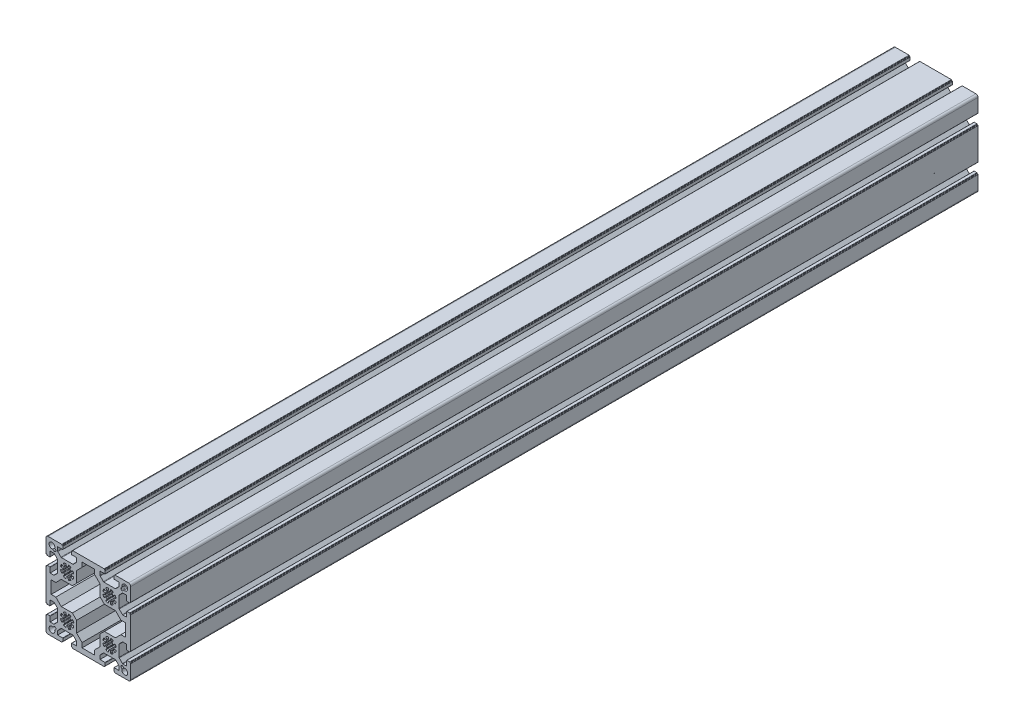
from build123d import *

# Parameters (mm, degrees)
EXTRUDE_1_DEPTH = 1000


with BuildPart() as part:
    # Эскиз1 → Бобышка-Вытянуть1 (new body)
    with BuildSketch(Plane.XY):
        with BuildLine():
            Line((-25, 11.25), (-25, 22.5))
            ThreePointArc((-25, 22.5), (-24.267766953, 24.267766953), (-22.5, 25))
            Line((-22.5, 25), (-11.25, 25))
            Line((-11.25, 25), (-6.4, 25))
            ThreePointArc((-6.4, 25), (-6.187867966, 24.912132034), (-6.1, 24.7))
            Line((-6.1, 24.7), (-6.1, 24.3))
            ThreePointArc((-6.1, 24.3), (-6.012132034, 24.087867966), (-5.8, 24))
            Line((-5.8, 24), (-5.4, 24))
            ThreePointArc((-5.4, 24), (-5.187867966, 23.912132034), (-5.1, 23.7))
            Line((-5.1, 23.7), (-5.1, 20.5))
            ThreePointArc((-5.1, 20.5), (-5.187867966, 20.287867966), (-5.4, 20.2))
            Line((-5.4, 20.2), (-11.25, 20.2))
            Line((-11.25, 20.2), (-11.25, 15.874213562))
            ThreePointArc((-11.25, 15.874213562), (-11.173879533, 15.49153013), (-10.957106781, 15.167106781))
            Line((-10.957106781, 15.167106781), (-7.292893219, 11.502893219))
            ThreePointArc((-7.292893219, 11.502893219), (-6.96846987, 11.286120467), (-6.585786438, 11.21))
            Line((-6.585786438, 11.21), (6.585786438, 11.21))
            ThreePointArc((6.585786438, 11.21), (6.96846987, 11.286120467), (7.292893219, 11.502893219))
            Line((7.292893219, 11.502893219), (10.957106781, 15.167106781))
            ThreePointArc((10.957106781, 15.167106781), (11.173879533, 15.49153013), (11.25, 15.874213562))
            Line((11.25, 15.874213562), (11.25, 20.2))
            Line((11.25, 20.2), (5.4, 20.2))
            ThreePointArc((5.4, 20.2), (5.187867966, 20.287867966), (5.1, 20.5))
            Line((5.1, 20.5), (5.1, 23.7))
            ThreePointArc((5.1, 23.7), (5.187867966, 23.912132034), (5.4, 24))
            Line((5.4, 24), (5.8, 24))
            ThreePointArc((5.8, 24), (6.012132034, 24.087867966), (6.1, 24.3))
            Line((6.1, 24.3), (6.1, 24.7))
            ThreePointArc((6.1, 24.7), (6.187867966, 24.912132034), (6.4, 25))
            Line((6.4, 25), (11.25, 25))
            Line((11.25, 25), (38.75, 25))
            Line((38.75, 25), (43.6, 25))
            ThreePointArc((43.6, 25), (43.812132034, 24.912132034), (43.9, 24.7))
            Line((43.9, 24.7), (43.9, 24.3))
            ThreePointArc((43.9, 24.3), (43.987867966, 24.087867966), (44.2, 24))
            Line((44.2, 24), (44.6, 24))
            ThreePointArc((44.6, 24), (44.812132034, 23.912132034), (44.9, 23.7))
            Line((44.9, 23.7), (44.9, 20.5))
            ThreePointArc((44.9, 20.5), (44.812132034, 20.287867966), (44.6, 20.2))
            Line((44.6, 20.2), (38.75, 20.2))
            Line((38.75, 20.2), (38.75, 15.874213562))
            ThreePointArc((38.75, 15.874213562), (38.826120467, 15.49153013), (39.042893219, 15.167106781))
            Line((39.042893219, 15.167106781), (42.707106781, 11.502893219))
            ThreePointArc((42.707106781, 11.502893219), (43.03153013, 11.286120467), (43.414213562, 11.21))
            Line((43.414213562, 11.21), (56.585786438, 11.21))
            ThreePointArc((56.585786438, 11.21), (56.96846987, 11.286120467), (57.292893219, 11.502893219))
            Line((57.292893219, 11.502893219), (60.957106781, 15.167106781))
            ThreePointArc((60.957106781, 15.167106781), (61.173879533, 15.49153013), (61.25, 15.874213562))
            Line((61.25, 15.874213562), (61.25, 20.2))
            Line((61.25, 20.2), (55.4, 20.2))
            ThreePointArc((55.4, 20.2), (55.187867966, 20.287867966), (55.1, 20.5))
            Line((55.1, 20.5), (55.1, 23.7))
            ThreePointArc((55.1, 23.7), (55.187867966, 23.912132034), (55.4, 24))
            Line((55.4, 24), (55.8, 24))
            ThreePointArc((55.8, 24), (56.012132034, 24.087867966), (56.1, 24.3))
            Line((56.1, 24.3), (56.1, 24.7))
            ThreePointArc((56.1, 24.7), (56.187867966, 24.912132034), (56.4, 25))
            Line((56.4, 25), (61.25, 25))
            Line((61.25, 25), (72.5, 25))
            ThreePointArc((72.5, 25), (74.267766953, 24.267766953), (75, 22.5))
            Line((75, 22.5), (75, 11.25))
            Line((75, 11.25), (75, 6.4))
            ThreePointArc((75, 6.4), (74.912132034, 6.187867966), (74.7, 6.1))
            Line((74.7, 6.1), (74.3, 6.1))
            ThreePointArc((74.3, 6.1), (74.087867966, 6.012132034), (74, 5.8))
            Line((74, 5.8), (74, 5.4))
            ThreePointArc((74, 5.4), (73.912132034, 5.187867966), (73.7, 5.1))
            Line((73.7, 5.1), (70.5, 5.1))
            ThreePointArc((70.5, 5.1), (70.287867966, 5.187867966), (70.2, 5.4))
            Line((70.2, 5.4), (70.2, 11.25))
            Line((70.2, 11.25), (65.874213562, 11.25))
            ThreePointArc((65.874213562, 11.25), (65.49153013, 11.173879533), (65.167106781, 10.957106781))
            Line((65.167106781, 10.957106781), (61.502893219, 7.292893219))
            ThreePointArc((61.502893219, 7.292893219), (61.286120467, 6.96846987), (61.21, 6.585786438))
            Line((61.21, 6.585786438), (61.21, -6.585786438))
            ThreePointArc((61.21, -6.585786438), (61.286120467, -6.96846987), (61.502893219, -7.292893219))
            Line((61.502893219, -7.292893219), (65.167106781, -10.957106781))
            ThreePointArc((65.167106781, -10.957106781), (65.49153013, -11.173879533), (65.874213562, -11.25))
            Line((65.874213562, -11.25), (70.2, -11.25))
            Line((70.2, -11.25), (70.2, -5.4))
            ThreePointArc((70.2, -5.4), (70.287867966, -5.187867966), (70.5, -5.1))
            Line((70.5, -5.1), (73.7, -5.1))
            ThreePointArc((73.7, -5.1), (73.912132034, -5.187867966), (74, -5.4))
            Line((74, -5.4), (74, -5.8))
            ThreePointArc((74, -5.8), (74.087867966, -6.012132034), (74.3, -6.1))
            Line((74.3, -6.1), (74.7, -6.1))
            ThreePointArc((74.7, -6.1), (74.912132034, -6.187867966), (75, -6.4))
            Line((75, -6.4), (75, -11.25))
            Line((75, -11.25), (75, -38.75))
            Line((75, -38.75), (75, -43.6))
            ThreePointArc((75, -43.6), (74.912132034, -43.812132034), (74.7, -43.9))
            Line((74.7, -43.9), (74.3, -43.9))
            ThreePointArc((74.3, -43.9), (74.087867966, -43.987867966), (74, -44.2))
            Line((74, -44.2), (74, -44.6))
            ThreePointArc((74, -44.6), (73.912132034, -44.812132034), (73.7, -44.9))
            Line((73.7, -44.9), (70.5, -44.9))
            ThreePointArc((70.5, -44.9), (70.287867966, -44.812132034), (70.2, -44.6))
            Line((70.2, -44.6), (70.2, -38.75))
            Line((70.2, -38.75), (65.874213562, -38.75))
            ThreePointArc((65.874213562, -38.75), (65.49153013, -38.826120467), (65.167106781, -39.042893219))
            Line((65.167106781, -39.042893219), (61.502893219, -42.707106781))
            ThreePointArc((61.502893219, -42.707106781), (61.286120467, -43.03153013), (61.21, -43.414213562))
            Line((61.21, -43.414213562), (61.21, -56.585786438))
            ThreePointArc((61.21, -56.585786438), (61.286120467, -56.96846987), (61.502893219, -57.292893219))
            Line((61.502893219, -57.292893219), (65.167106781, -60.957106781))
            ThreePointArc((65.167106781, -60.957106781), (65.49153013, -61.173879533), (65.874213562, -61.25))
            Line((65.874213562, -61.25), (70.2, -61.25))
            Line((70.2, -61.25), (70.2, -55.4))
            ThreePointArc((70.2, -55.4), (70.287867966, -55.187867966), (70.5, -55.1))
            Line((70.5, -55.1), (73.7, -55.1))
            ThreePointArc((73.7, -55.1), (73.912132034, -55.187867966), (74, -55.4))
            Line((74, -55.4), (74, -55.8))
            ThreePointArc((74, -55.8), (74.087867966, -56.012132034), (74.3, -56.1))
            Line((74.3, -56.1), (74.7, -56.1))
            ThreePointArc((74.7, -56.1), (74.912132034, -56.187867966), (75, -56.4))
            Line((75, -56.4), (75, -61.25))
            Line((75, -61.25), (75, -72.5))
            ThreePointArc((75, -72.5), (74.267766953, -74.267766953), (72.5, -75))
            Line((72.5, -75), (61.25, -75))
            Line((61.25, -75), (56.4, -75))
            ThreePointArc((56.4, -75), (56.187867966, -74.912132034), (56.1, -74.7))
            Line((56.1, -74.7), (56.1, -74.3))
            ThreePointArc((56.1, -74.3), (56.012132034, -74.087867966), (55.8, -74))
            Line((55.8, -74), (55.4, -74))
            ThreePointArc((55.4, -74), (55.187867966, -73.912132034), (55.1, -73.7))
            Line((55.1, -73.7), (55.1, -70.5))
            ThreePointArc((55.1, -70.5), (55.187867966, -70.287867966), (55.4, -70.2))
            Line((55.4, -70.2), (61.25, -70.2))
            Line((61.25, -70.2), (61.25, -65.874213562))
            ThreePointArc((61.25, -65.874213562), (61.173879533, -65.49153013), (60.957106781, -65.167106781))
            Line((60.957106781, -65.167106781), (57.292893219, -61.502893219))
            ThreePointArc((57.292893219, -61.502893219), (56.96846987, -61.286120467), (56.585786438, -61.21))
            Line((56.585786438, -61.21), (43.414213562, -61.21))
            ThreePointArc((43.414213562, -61.21), (43.03153013, -61.286120467), (42.707106781, -61.502893219))
            Line((42.707106781, -61.502893219), (39.042893219, -65.167106781))
            ThreePointArc((39.042893219, -65.167106781), (38.826120467, -65.49153013), (38.75, -65.874213562))
            Line((38.75, -65.874213562), (38.75, -70.2))
            Line((38.75, -70.2), (44.6, -70.2))
            ThreePointArc((44.6, -70.2), (44.812132034, -70.287867966), (44.9, -70.5))
            Line((44.9, -70.5), (44.9, -73.7))
            ThreePointArc((44.9, -73.7), (44.812132034, -73.912132034), (44.6, -74))
            Line((44.6, -74), (44.2, -74))
            ThreePointArc((44.2, -74), (43.987867966, -74.087867966), (43.9, -74.3))
            Line((43.9, -74.3), (43.9, -74.7))
            ThreePointArc((43.9, -74.7), (43.812132034, -74.912132034), (43.6, -75))
            Line((43.6, -75), (38.75, -75))
            Line((38.75, -75), (11.25, -75))
            Line((11.25, -75), (6.4, -75))
            ThreePointArc((6.4, -75), (6.187867966, -74.912132034), (6.1, -74.7))
            Line((6.1, -74.7), (6.1, -74.3))
            ThreePointArc((6.1, -74.3), (6.012132034, -74.087867966), (5.8, -74))
            Line((5.8, -74), (5.4, -74))
            ThreePointArc((5.4, -74), (5.187867966, -73.912132034), (5.1, -73.7))
            Line((5.1, -73.7), (5.1, -70.5))
            ThreePointArc((5.1, -70.5), (5.187867966, -70.287867966), (5.4, -70.2))
            Line((5.4, -70.2), (11.25, -70.2))
            Line((11.25, -70.2), (11.25, -65.874213562))
            ThreePointArc((11.25, -65.874213562), (11.173879533, -65.49153013), (10.957106781, -65.167106781))
            Line((10.957106781, -65.167106781), (7.292893219, -61.502893219))
            ThreePointArc((7.292893219, -61.502893219), (6.96846987, -61.286120467), (6.585786438, -61.21))
            Line((6.585786438, -61.21), (-6.585786438, -61.21))
            ThreePointArc((-6.585786438, -61.21), (-6.96846987, -61.286120467), (-7.292893219, -61.502893219))
            Line((-7.292893219, -61.502893219), (-10.957106781, -65.167106781))
            ThreePointArc((-10.957106781, -65.167106781), (-11.173879533, -65.49153013), (-11.25, -65.874213562))
            Line((-11.25, -65.874213562), (-11.25, -70.2))
            Line((-11.25, -70.2), (-5.4, -70.2))
            ThreePointArc((-5.4, -70.2), (-5.187867966, -70.287867966), (-5.1, -70.5))
            Line((-5.1, -70.5), (-5.1, -73.7))
            ThreePointArc((-5.1, -73.7), (-5.187867966, -73.912132034), (-5.4, -74))
            Line((-5.4, -74), (-5.8, -74))
            ThreePointArc((-5.8, -74), (-6.012132034, -74.087867966), (-6.1, -74.3))
            Line((-6.1, -74.3), (-6.1, -74.7))
            ThreePointArc((-6.1, -74.7), (-6.187867966, -74.912132034), (-6.4, -75))
            Line((-6.4, -75), (-11.25, -75))
            Line((-11.25, -75), (-22.5, -75))
            ThreePointArc((-22.5, -75), (-24.267766953, -74.267766953), (-25, -72.5))
            Line((-25, -72.5), (-25, -61.25))
            Line((-25, -61.25), (-25, -56.4))
            ThreePointArc((-25, -56.4), (-24.912132034, -56.187867966), (-24.7, -56.1))
            Line((-24.7, -56.1), (-24.3, -56.1))
            ThreePointArc((-24.3, -56.1), (-24.087867966, -56.012132034), (-24, -55.8))
            Line((-24, -55.8), (-24, -55.4))
            ThreePointArc((-24, -55.4), (-23.912132034, -55.187867966), (-23.7, -55.1))
            Line((-23.7, -55.1), (-20.5, -55.1))
            ThreePointArc((-20.5, -55.1), (-20.287867966, -55.187867966), (-20.2, -55.4))
            Line((-20.2, -55.4), (-20.2, -61.25))
            Line((-20.2, -61.25), (-15.874213562, -61.25))
            ThreePointArc((-15.874213562, -61.25), (-15.49153013, -61.173879533), (-15.167106781, -60.957106781))
            Line((-15.167106781, -60.957106781), (-11.502893219, -57.292893219))
            ThreePointArc((-11.502893219, -57.292893219), (-11.286120467, -56.96846987), (-11.21, -56.585786438))
            Line((-11.21, -56.585786438), (-11.21, -43.414213562))
            ThreePointArc((-11.21, -43.414213562), (-11.286120467, -43.03153013), (-11.502893219, -42.707106781))
            Line((-11.502893219, -42.707106781), (-15.167106781, -39.042893219))
            ThreePointArc((-15.167106781, -39.042893219), (-15.49153013, -38.826120467), (-15.874213562, -38.75))
            Line((-15.874213562, -38.75), (-20.2, -38.75))
            Line((-20.2, -38.75), (-20.2, -44.6))
            ThreePointArc((-20.2, -44.6), (-20.287867966, -44.812132034), (-20.5, -44.9))
            Line((-20.5, -44.9), (-23.7, -44.9))
            ThreePointArc((-23.7, -44.9), (-23.912132034, -44.812132034), (-24, -44.6))
            Line((-24, -44.6), (-24, -44.2))
            ThreePointArc((-24, -44.2), (-24.087867966, -43.987867966), (-24.3, -43.9))
            Line((-24.3, -43.9), (-24.7, -43.9))
            ThreePointArc((-24.7, -43.9), (-24.912132034, -43.812132034), (-25, -43.6))
            Line((-25, -43.6), (-25, -38.75))
            Line((-25, -38.75), (-25, -11.25))
            Line((-25, -11.25), (-25, -6.4))
            ThreePointArc((-25, -6.4), (-24.912132034, -6.187867966), (-24.7, -6.1))
            Line((-24.7, -6.1), (-24.3, -6.1))
            ThreePointArc((-24.3, -6.1), (-24.087867966, -6.012132034), (-24, -5.8))
            Line((-24, -5.8), (-24, -5.4))
            ThreePointArc((-24, -5.4), (-23.912132034, -5.187867966), (-23.7, -5.1))
            Line((-23.7, -5.1), (-20.5, -5.1))
            ThreePointArc((-20.5, -5.1), (-20.287867966, -5.187867966), (-20.2, -5.4))
            Line((-20.2, -5.4), (-20.2, -11.25))
            Line((-20.2, -11.25), (-15.874213562, -11.25))
            ThreePointArc((-15.874213562, -11.25), (-15.49153013, -11.173879533), (-15.167106781, -10.957106781))
            Line((-15.167106781, -10.957106781), (-11.502893219, -7.292893219))
            ThreePointArc((-11.502893219, -7.292893219), (-11.286120467, -6.96846987), (-11.21, -6.585786438))
            Line((-11.21, -6.585786438), (-11.21, 6.585786438))
            ThreePointArc((-11.21, 6.585786438), (-11.286120467, 6.96846987), (-11.502893219, 7.292893219))
            Line((-11.502893219, 7.292893219), (-15.167106781, 10.957106781))
            ThreePointArc((-15.167106781, 10.957106781), (-15.49153013, 11.173879533), (-15.874213562, 11.25))
            Line((-15.874213562, 11.25), (-20.2, 11.25))
            Line((-20.2, 11.25), (-20.2, 5.4))
            ThreePointArc((-20.2, 5.4), (-20.287867966, 5.187867966), (-20.5, 5.1))
            Line((-20.5, 5.1), (-23.7, 5.1))
            ThreePointArc((-23.7, 5.1), (-23.912132034, 5.187867966), (-24, 5.4))
            Line((-24, 5.4), (-24, 5.8))
            ThreePointArc((-24, 5.8), (-24.087867966, 6.012132034), (-24.3, 6.1))
            Line((-24.3, 6.1), (-24.7, 6.1))
            ThreePointArc((-24.7, 6.1), (-24.912132034, 6.187867966), (-25, 6.4))
            Line((-25, 6.4), (-25, 11.25))
        make_face()
        Polygon((-18.9, -32.45), (-18.9, -17.55), (-13.416139982, -17.55), (-6.966139982, -11.1), (6.1, -11.1), (11.1, -6.1), (11.1, 6.966139982), (17.55, 13.416139982), (17.55, 18.9), (32.45, 18.9), (32.45, 13.416139982), (38.9, 6.966139982), (38.9, -6.1), (43.9, -11.1), (56.966139982, -11.1), (63.416139982, -17.55), (68.9, -17.55), (68.9, -32.45), (63.416139982, -32.45), (56.966139982, -38.9), (43.9, -38.9), (38.9, -43.9), (38.9, -56.966139982), (32.45, -63.416139982), (32.45, -68.9), (17.55, -68.9), (17.55, -63.416139982), (11.1, -56.966139982), (11.1, -43.9), (6.1, -38.9), (-6.966139982, -38.9), (-13.416139982, -32.45), align=None, mode=Mode.SUBTRACT)
        with BuildLine():
            Line((-16.903115271, 14.781794927), (-15.666547622, 13.545227279))
            ThreePointArc((-15.666547622, 13.545227279), (-14.959440841, 13.25233406), (-14.25233406, 13.545227279))
            Line((-14.25233406, 13.545227279), (-13.545227279, 14.25233406))
            ThreePointArc((-13.545227279, 14.25233406), (-13.25233406, 14.959440841), (-13.545227279, 15.666547622))
            Line((-13.545227279, 15.666547622), (-14.781794927, 16.903115271))
            ThreePointArc((-14.781794927, 16.903115271), (-20.404163056, 20.404163056), (-16.903115271, 14.781794927))
        make_face(mode=Mode.SUBTRACT)
        with BuildLine():
            Line((64.781794927, 16.903115271), (63.545227279, 15.666547622))
            ThreePointArc((63.545227279, 15.666547622), (63.25233406, 14.959440841), (63.545227279, 14.25233406))
            Line((63.545227279, 14.25233406), (64.25233406, 13.545227279))
            ThreePointArc((64.25233406, 13.545227279), (64.959440841, 13.25233406), (65.666547622, 13.545227279))
            Line((65.666547622, 13.545227279), (66.903115271, 14.781794927))
            ThreePointArc((66.903115271, 14.781794927), (70.404163056, 20.404163056), (64.781794927, 16.903115271))
        make_face(mode=Mode.SUBTRACT)
        with BuildLine():
            Line((66.903115271, -64.781794927), (65.666547622, -63.545227279))
            ThreePointArc((65.666547622, -63.545227279), (64.959440841, -63.25233406), (64.25233406, -63.545227279))
            Line((64.25233406, -63.545227279), (63.545227279, -64.25233406))
            ThreePointArc((63.545227279, -64.25233406), (63.25233406, -64.959440841), (63.545227279, -65.666547622))
            Line((63.545227279, -65.666547622), (64.781794927, -66.903115271))
            ThreePointArc((64.781794927, -66.903115271), (70.404163056, -70.404163056), (66.903115271, -64.781794927))
        make_face(mode=Mode.SUBTRACT)
        with BuildLine():
            Line((-14.781794927, -66.903115271), (-13.545227279, -65.666547622))
            ThreePointArc((-13.545227279, -65.666547622), (-13.25233406, -64.959440841), (-13.545227279, -64.25233406))
            Line((-13.545227279, -64.25233406), (-14.25233406, -63.545227279))
            ThreePointArc((-14.25233406, -63.545227279), (-14.959440841, -63.25233406), (-15.666547622, -63.545227279))
            Line((-15.666547622, -63.545227279), (-16.903115271, -64.781794927))
            ThreePointArc((-16.903115271, -64.781794927), (-20.404163056, -70.404163056), (-14.781794927, -66.903115271))
        make_face(mode=Mode.SUBTRACT)
        with BuildLine():
            Line((1.3637258, 7.358005976), (1.016443046, 5.484235912))
            ThreePointArc((1.016443046, 5.484235912), (0.826149864, 5.176357864), (0.477957057, 5.077554239))
            ThreePointArc((0.477957057, 5.077554239), (0, 5.1), (-0.477957057, 5.077554239))
            ThreePointArc((-0.477957057, 5.077554239), (-0.826149864, 5.176357864), (-1.016443046, 5.484235912))
            Line((-1.016443046, 5.484235912), (-1.3637258, 7.358005976))
            ThreePointArc((-1.3637258, 7.358005976), (-1.586050772, 7.688167424), (-1.979043471, 7.751347427))
            ThreePointArc((-1.979043471, 7.751347427), (-3.061467459, 7.39103626), (-4.081635271, 6.880425388))
            ThreePointArc((-4.081635271, 6.880425388), (-4.314848064, 6.557862576), (-4.238596161, 6.167195683))
            Line((-4.238596161, 6.167195683), (-3.159206632, 4.596674173))
            ThreePointArc((-3.159206632, 4.596674173), (-3.076061576, 4.244413919), (-3.252406358, 3.928339711))
            ThreePointArc((-3.252406358, 3.928339711), (-3.606244584, 3.606244584), (-3.928339711, 3.252406358))
            ThreePointArc((-3.928339711, 3.252406358), (-4.244413919, 3.076061576), (-4.596674173, 3.159206632))
            Line((-4.596674173, 3.159206632), (-6.167195683, 4.238596161))
            ThreePointArc((-6.167195683, 4.238596161), (-6.557862576, 4.314848064), (-6.880425388, 4.081635271))
            ThreePointArc((-6.880425388, 4.081635271), (-7.39103626, 3.061467459), (-7.751347427, 1.979043471))
            ThreePointArc((-7.751347427, 1.979043471), (-7.688167424, 1.586050772), (-7.358005976, 1.3637258))
            Line((-7.358005976, 1.3637258), (-5.484235912, 1.016443046))
            ThreePointArc((-5.484235912, 1.016443046), (-5.176357864, 0.826149864), (-5.077554239, 0.477957057))
            ThreePointArc((-5.077554239, 0.477957057), (-5.1, 0), (-5.077554239, -0.477957057))
            ThreePointArc((-5.077554239, -0.477957057), (-5.176357864, -0.826149864), (-5.484235912, -1.016443046))
            Line((-5.484235912, -1.016443046), (-7.358005976, -1.3637258))
            ThreePointArc((-7.358005976, -1.3637258), (-7.688167424, -1.586050772), (-7.751347427, -1.979043471))
            ThreePointArc((-7.751347427, -1.979043471), (-7.39103626, -3.061467459), (-6.880425388, -4.081635271))
            ThreePointArc((-6.880425388, -4.081635271), (-6.557862576, -4.314848064), (-6.167195683, -4.238596161))
            Line((-6.167195683, -4.238596161), (-4.596674173, -3.159206632))
            ThreePointArc((-4.596674173, -3.159206632), (-4.244413919, -3.076061576), (-3.928339711, -3.252406358))
            ThreePointArc((-3.928339711, -3.252406358), (-3.606244584, -3.606244584), (-3.252406358, -3.928339711))
            ThreePointArc((-3.252406358, -3.928339711), (-3.076061576, -4.244413919), (-3.159206632, -4.596674173))
            Line((-3.159206632, -4.596674173), (-4.238596161, -6.167195683))
            ThreePointArc((-4.238596161, -6.167195683), (-4.314848064, -6.557862576), (-4.081635271, -6.880425388))
            ThreePointArc((-4.081635271, -6.880425388), (-3.061467459, -7.39103626), (-1.979043471, -7.751347427))
            ThreePointArc((-1.979043471, -7.751347427), (-1.586050772, -7.688167424), (-1.3637258, -7.358005976))
            Line((-1.3637258, -7.358005976), (-1.016443046, -5.484235912))
            ThreePointArc((-1.016443046, -5.484235912), (-0.826149864, -5.176357864), (-0.477957057, -5.077554239))
            ThreePointArc((-0.477957057, -5.077554239), (0, -5.1), (0.477957057, -5.077554239))
            ThreePointArc((0.477957057, -5.077554239), (0.826149864, -5.176357864), (1.016443046, -5.484235912))
            Line((1.016443046, -5.484235912), (1.3637258, -7.358005976))
            ThreePointArc((1.3637258, -7.358005976), (1.586050772, -7.688167424), (1.979043471, -7.751347427))
            ThreePointArc((1.979043471, -7.751347427), (3.061467459, -7.39103626), (4.081635271, -6.880425388))
            ThreePointArc((4.081635271, -6.880425388), (4.314848064, -6.557862576), (4.238596161, -6.167195683))
            Line((4.238596161, -6.167195683), (3.159206632, -4.596674173))
            ThreePointArc((3.159206632, -4.596674173), (3.076061576, -4.244413919), (3.252406358, -3.928339711))
            ThreePointArc((3.252406358, -3.928339711), (3.606244584, -3.606244584), (3.928339711, -3.252406358))
            ThreePointArc((3.928339711, -3.252406358), (4.244413919, -3.076061576), (4.596674173, -3.159206632))
            Line((4.596674173, -3.159206632), (6.167195683, -4.238596161))
            ThreePointArc((6.167195683, -4.238596161), (6.557862576, -4.314848064), (6.880425388, -4.081635271))
            ThreePointArc((6.880425388, -4.081635271), (7.39103626, -3.061467459), (7.751347427, -1.979043471))
            ThreePointArc((7.751347427, -1.979043471), (7.688167424, -1.586050772), (7.358005976, -1.3637258))
            Line((7.358005976, -1.3637258), (5.484235912, -1.016443046))
            ThreePointArc((5.484235912, -1.016443046), (5.176357864, -0.826149864), (5.077554239, -0.477957057))
            ThreePointArc((5.077554239, -0.477957057), (5.1, 0), (5.077554239, 0.477957057))
            ThreePointArc((5.077554239, 0.477957057), (5.176357864, 0.826149864), (5.484235912, 1.016443046))
            Line((5.484235912, 1.016443046), (7.358005976, 1.3637258))
            ThreePointArc((7.358005976, 1.3637258), (7.688167424, 1.586050772), (7.751347427, 1.979043471))
            ThreePointArc((7.751347427, 1.979043471), (7.39103626, 3.061467459), (6.880425388, 4.081635271))
            ThreePointArc((6.880425388, 4.081635271), (6.557862576, 4.314848064), (6.167195683, 4.238596161))
            Line((6.167195683, 4.238596161), (4.596674173, 3.159206632))
            ThreePointArc((4.596674173, 3.159206632), (4.244413919, 3.076061576), (3.928339711, 3.252406358))
            ThreePointArc((3.928339711, 3.252406358), (3.606244584, 3.606244584), (3.252406358, 3.928339711))
            ThreePointArc((3.252406358, 3.928339711), (3.076061576, 4.244413919), (3.159206632, 4.596674173))
            Line((3.159206632, 4.596674173), (4.238596161, 6.167195683))
            ThreePointArc((4.238596161, 6.167195683), (4.314848064, 6.557862576), (4.081635271, 6.880425388))
            ThreePointArc((4.081635271, 6.880425388), (3.061467459, 7.39103626), (1.979043471, 7.751347427))
            ThreePointArc((1.979043471, 7.751347427), (1.586050772, 7.688167424), (1.3637258, 7.358005976))
        make_face(mode=Mode.SUBTRACT)
        with BuildLine():
            Line((48.6362742, 7.358005976), (48.983556954, 5.484235912))
            ThreePointArc((48.983556954, 5.484235912), (49.173850136, 5.176357864), (49.522042943, 5.077554239))
            ThreePointArc((49.522042943, 5.077554239), (50, 5.1), (50.477957057, 5.077554239))
            ThreePointArc((50.477957057, 5.077554239), (50.826149864, 5.176357864), (51.016443046, 5.484235912))
            Line((51.016443046, 5.484235912), (51.3637258, 7.358005976))
            ThreePointArc((51.3637258, 7.358005976), (51.586050772, 7.688167424), (51.979043471, 7.751347427))
            ThreePointArc((51.979043471, 7.751347427), (53.061467459, 7.39103626), (54.081635271, 6.880425388))
            ThreePointArc((54.081635271, 6.880425388), (54.314848064, 6.557862576), (54.238596161, 6.167195683))
            Line((54.238596161, 6.167195683), (53.159206632, 4.596674173))
            ThreePointArc((53.159206632, 4.596674173), (53.076061576, 4.244413919), (53.252406358, 3.928339711))
            ThreePointArc((53.252406358, 3.928339711), (53.606244584, 3.606244584), (53.928339711, 3.252406358))
            ThreePointArc((53.928339711, 3.252406358), (54.244413919, 3.076061576), (54.596674173, 3.159206632))
            Line((54.596674173, 3.159206632), (56.167195683, 4.238596161))
            ThreePointArc((56.167195683, 4.238596161), (56.557862576, 4.314848064), (56.880425388, 4.081635271))
            ThreePointArc((56.880425388, 4.081635271), (57.39103626, 3.061467459), (57.751347427, 1.979043471))
            ThreePointArc((57.751347427, 1.979043471), (57.688167424, 1.586050772), (57.358005976, 1.3637258))
            Line((57.358005976, 1.3637258), (55.484235912, 1.016443046))
            ThreePointArc((55.484235912, 1.016443046), (55.176357864, 0.826149864), (55.077554239, 0.477957057))
            ThreePointArc((55.077554239, 0.477957057), (55.1, 0), (55.077554239, -0.477957057))
            ThreePointArc((55.077554239, -0.477957057), (55.176357864, -0.826149864), (55.484235912, -1.016443046))
            Line((55.484235912, -1.016443046), (57.358005976, -1.3637258))
            ThreePointArc((57.358005976, -1.3637258), (57.688167424, -1.586050772), (57.751347427, -1.979043471))
            ThreePointArc((57.751347427, -1.979043471), (57.39103626, -3.061467459), (56.880425388, -4.081635271))
            ThreePointArc((56.880425388, -4.081635271), (56.557862576, -4.314848064), (56.167195683, -4.238596161))
            Line((56.167195683, -4.238596161), (54.596674173, -3.159206632))
            ThreePointArc((54.596674173, -3.159206632), (54.244413919, -3.076061576), (53.928339711, -3.252406358))
            ThreePointArc((53.928339711, -3.252406358), (53.606244584, -3.606244584), (53.252406358, -3.928339711))
            ThreePointArc((53.252406358, -3.928339711), (53.076061576, -4.244413919), (53.159206632, -4.596674173))
            Line((53.159206632, -4.596674173), (54.238596161, -6.167195683))
            ThreePointArc((54.238596161, -6.167195683), (54.314848064, -6.557862576), (54.081635271, -6.880425388))
            ThreePointArc((54.081635271, -6.880425388), (53.061467459, -7.39103626), (51.979043471, -7.751347427))
            ThreePointArc((51.979043471, -7.751347427), (51.586050772, -7.688167424), (51.3637258, -7.358005976))
            Line((51.3637258, -7.358005976), (51.016443046, -5.484235912))
            ThreePointArc((51.016443046, -5.484235912), (50.826149864, -5.176357864), (50.477957057, -5.077554239))
            ThreePointArc((50.477957057, -5.077554239), (50, -5.1), (49.522042943, -5.077554239))
            ThreePointArc((49.522042943, -5.077554239), (49.173850136, -5.176357864), (48.983556954, -5.484235912))
            Line((48.983556954, -5.484235912), (48.6362742, -7.358005976))
            ThreePointArc((48.6362742, -7.358005976), (48.413949228, -7.688167424), (48.020956529, -7.751347427))
            ThreePointArc((48.020956529, -7.751347427), (46.938532541, -7.39103626), (45.918364729, -6.880425388))
            ThreePointArc((45.918364729, -6.880425388), (45.685151936, -6.557862576), (45.761403839, -6.167195683))
            Line((45.761403839, -6.167195683), (46.840793368, -4.596674173))
            ThreePointArc((46.840793368, -4.596674173), (46.923938424, -4.244413919), (46.747593642, -3.928339711))
            ThreePointArc((46.747593642, -3.928339711), (46.393755416, -3.606244584), (46.071660289, -3.252406358))
            ThreePointArc((46.071660289, -3.252406358), (45.755586081, -3.076061576), (45.403325827, -3.159206632))
            Line((45.403325827, -3.159206632), (43.832804317, -4.238596161))
            ThreePointArc((43.832804317, -4.238596161), (43.442137424, -4.314848064), (43.119574612, -4.081635271))
            ThreePointArc((43.119574612, -4.081635271), (42.60896374, -3.061467459), (42.248652573, -1.979043471))
            ThreePointArc((42.248652573, -1.979043471), (42.311832576, -1.586050772), (42.641994024, -1.3637258))
            Line((42.641994024, -1.3637258), (44.515764088, -1.016443046))
            ThreePointArc((44.515764088, -1.016443046), (44.823642136, -0.826149864), (44.922445761, -0.477957057))
            ThreePointArc((44.922445761, -0.477957057), (44.9, 0), (44.922445761, 0.477957057))
            ThreePointArc((44.922445761, 0.477957057), (44.823642136, 0.826149864), (44.515764088, 1.016443046))
            Line((44.515764088, 1.016443046), (42.641994024, 1.3637258))
            ThreePointArc((42.641994024, 1.3637258), (42.311832576, 1.586050772), (42.248652573, 1.979043471))
            ThreePointArc((42.248652573, 1.979043471), (42.60896374, 3.061467459), (43.119574612, 4.081635271))
            ThreePointArc((43.119574612, 4.081635271), (43.442137424, 4.314848064), (43.832804317, 4.238596161))
            Line((43.832804317, 4.238596161), (45.403325827, 3.159206632))
            ThreePointArc((45.403325827, 3.159206632), (45.755586081, 3.076061576), (46.071660289, 3.252406358))
            ThreePointArc((46.071660289, 3.252406358), (46.393755416, 3.606244584), (46.747593642, 3.928339711))
            ThreePointArc((46.747593642, 3.928339711), (46.923938424, 4.244413919), (46.840793368, 4.596674173))
            Line((46.840793368, 4.596674173), (45.761403839, 6.167195683))
            ThreePointArc((45.761403839, 6.167195683), (45.685151936, 6.557862576), (45.918364729, 6.880425388))
            ThreePointArc((45.918364729, 6.880425388), (46.938532541, 7.39103626), (48.020956529, 7.751347427))
            ThreePointArc((48.020956529, 7.751347427), (48.413949228, 7.688167424), (48.6362742, 7.358005976))
        make_face(mode=Mode.SUBTRACT)
        with BuildLine():
            Line((1.3637258, -57.358005976), (1.016443046, -55.484235912))
            ThreePointArc((1.016443046, -55.484235912), (0.826149864, -55.176357864), (0.477957057, -55.077554239))
            ThreePointArc((0.477957057, -55.077554239), (0, -55.1), (-0.477957057, -55.077554239))
            ThreePointArc((-0.477957057, -55.077554239), (-0.826149864, -55.176357864), (-1.016443046, -55.484235912))
            Line((-1.016443046, -55.484235912), (-1.3637258, -57.358005976))
            ThreePointArc((-1.3637258, -57.358005976), (-1.586050772, -57.688167424), (-1.979043471, -57.751347427))
            ThreePointArc((-1.979043471, -57.751347427), (-3.061467459, -57.39103626), (-4.081635271, -56.880425388))
            ThreePointArc((-4.081635271, -56.880425388), (-4.314848064, -56.557862576), (-4.238596161, -56.167195683))
            Line((-4.238596161, -56.167195683), (-3.159206632, -54.596674173))
            ThreePointArc((-3.159206632, -54.596674173), (-3.076061576, -54.244413919), (-3.252406358, -53.928339711))
            ThreePointArc((-3.252406358, -53.928339711), (-3.606244584, -53.606244584), (-3.928339711, -53.252406358))
            ThreePointArc((-3.928339711, -53.252406358), (-4.244413919, -53.076061576), (-4.596674173, -53.159206632))
            Line((-4.596674173, -53.159206632), (-6.167195683, -54.238596161))
            ThreePointArc((-6.167195683, -54.238596161), (-6.557862576, -54.314848064), (-6.880425388, -54.081635271))
            ThreePointArc((-6.880425388, -54.081635271), (-7.39103626, -53.061467459), (-7.751347427, -51.979043471))
            ThreePointArc((-7.751347427, -51.979043471), (-7.688167424, -51.586050772), (-7.358005976, -51.3637258))
            Line((-7.358005976, -51.3637258), (-5.484235912, -51.016443046))
            ThreePointArc((-5.484235912, -51.016443046), (-5.176357864, -50.826149864), (-5.077554239, -50.477957057))
            ThreePointArc((-5.077554239, -50.477957057), (-5.1, -50), (-5.077554239, -49.522042943))
            ThreePointArc((-5.077554239, -49.522042943), (-5.176357864, -49.173850136), (-5.484235912, -48.983556954))
            Line((-5.484235912, -48.983556954), (-7.358005976, -48.6362742))
            ThreePointArc((-7.358005976, -48.6362742), (-7.688167424, -48.413949228), (-7.751347427, -48.020956529))
            ThreePointArc((-7.751347427, -48.020956529), (-7.39103626, -46.938532541), (-6.880425388, -45.918364729))
            ThreePointArc((-6.880425388, -45.918364729), (-6.557862576, -45.685151936), (-6.167195683, -45.761403839))
            Line((-6.167195683, -45.761403839), (-4.596674173, -46.840793368))
            ThreePointArc((-4.596674173, -46.840793368), (-4.244413919, -46.923938424), (-3.928339711, -46.747593642))
            ThreePointArc((-3.928339711, -46.747593642), (-3.606244584, -46.393755416), (-3.252406358, -46.071660289))
            ThreePointArc((-3.252406358, -46.071660289), (-3.076061576, -45.755586081), (-3.159206632, -45.403325827))
            Line((-3.159206632, -45.403325827), (-4.238596161, -43.832804317))
            ThreePointArc((-4.238596161, -43.832804317), (-4.314848064, -43.442137424), (-4.081635271, -43.119574612))
            ThreePointArc((-4.081635271, -43.119574612), (-3.061467459, -42.60896374), (-1.979043471, -42.248652573))
            ThreePointArc((-1.979043471, -42.248652573), (-1.586050772, -42.311832576), (-1.3637258, -42.641994024))
            Line((-1.3637258, -42.641994024), (-1.016443046, -44.515764088))
            ThreePointArc((-1.016443046, -44.515764088), (-0.826149864, -44.823642136), (-0.477957057, -44.922445761))
            ThreePointArc((-0.477957057, -44.922445761), (0, -44.9), (0.477957057, -44.922445761))
            ThreePointArc((0.477957057, -44.922445761), (0.826149864, -44.823642136), (1.016443046, -44.515764088))
            Line((1.016443046, -44.515764088), (1.3637258, -42.641994024))
            ThreePointArc((1.3637258, -42.641994024), (1.586050772, -42.311832576), (1.979043471, -42.248652573))
            ThreePointArc((1.979043471, -42.248652573), (3.061467459, -42.60896374), (4.081635271, -43.119574612))
            ThreePointArc((4.081635271, -43.119574612), (4.314848064, -43.442137424), (4.238596161, -43.832804317))
            Line((4.238596161, -43.832804317), (3.159206632, -45.403325827))
            ThreePointArc((3.159206632, -45.403325827), (3.076061576, -45.755586081), (3.252406358, -46.071660289))
            ThreePointArc((3.252406358, -46.071660289), (3.606244584, -46.393755416), (3.928339711, -46.747593642))
            ThreePointArc((3.928339711, -46.747593642), (4.244413919, -46.923938424), (4.596674173, -46.840793368))
            Line((4.596674173, -46.840793368), (6.167195683, -45.761403839))
            ThreePointArc((6.167195683, -45.761403839), (6.557862576, -45.685151936), (6.880425388, -45.918364729))
            ThreePointArc((6.880425388, -45.918364729), (7.39103626, -46.938532541), (7.751347427, -48.020956529))
            ThreePointArc((7.751347427, -48.020956529), (7.688167424, -48.413949228), (7.358005976, -48.6362742))
            Line((7.358005976, -48.6362742), (5.484235912, -48.983556954))
            ThreePointArc((5.484235912, -48.983556954), (5.176357864, -49.173850136), (5.077554239, -49.522042943))
            ThreePointArc((5.077554239, -49.522042943), (5.1, -50), (5.077554239, -50.477957057))
            ThreePointArc((5.077554239, -50.477957057), (5.176357864, -50.826149864), (5.484235912, -51.016443046))
            Line((5.484235912, -51.016443046), (7.358005976, -51.3637258))
            ThreePointArc((7.358005976, -51.3637258), (7.688167424, -51.586050772), (7.751347427, -51.979043471))
            ThreePointArc((7.751347427, -51.979043471), (7.39103626, -53.061467459), (6.880425388, -54.081635271))
            ThreePointArc((6.880425388, -54.081635271), (6.557862576, -54.314848064), (6.167195683, -54.238596161))
            Line((6.167195683, -54.238596161), (4.596674173, -53.159206632))
            ThreePointArc((4.596674173, -53.159206632), (4.244413919, -53.076061576), (3.928339711, -53.252406358))
            ThreePointArc((3.928339711, -53.252406358), (3.606244584, -53.606244584), (3.252406358, -53.928339711))
            ThreePointArc((3.252406358, -53.928339711), (3.076061576, -54.244413919), (3.159206632, -54.596674173))
            Line((3.159206632, -54.596674173), (4.238596161, -56.167195683))
            ThreePointArc((4.238596161, -56.167195683), (4.314848064, -56.557862576), (4.081635271, -56.880425388))
            ThreePointArc((4.081635271, -56.880425388), (3.061467459, -57.39103626), (1.979043471, -57.751347427))
            ThreePointArc((1.979043471, -57.751347427), (1.586050772, -57.688167424), (1.3637258, -57.358005976))
        make_face(mode=Mode.SUBTRACT)
        with BuildLine():
            Line((48.6362742, -57.358005976), (48.983556954, -55.484235912))
            ThreePointArc((48.983556954, -55.484235912), (49.173850136, -55.176357864), (49.522042943, -55.077554239))
            ThreePointArc((49.522042943, -55.077554239), (50, -55.1), (50.477957057, -55.077554239))
            ThreePointArc((50.477957057, -55.077554239), (50.826149864, -55.176357864), (51.016443046, -55.484235912))
            Line((51.016443046, -55.484235912), (51.3637258, -57.358005976))
            ThreePointArc((51.3637258, -57.358005976), (51.586050772, -57.688167424), (51.979043471, -57.751347427))
            ThreePointArc((51.979043471, -57.751347427), (53.061467459, -57.39103626), (54.081635271, -56.880425388))
            ThreePointArc((54.081635271, -56.880425388), (54.314848064, -56.557862576), (54.238596161, -56.167195683))
            Line((54.238596161, -56.167195683), (53.159206632, -54.596674173))
            ThreePointArc((53.159206632, -54.596674173), (53.076061576, -54.244413919), (53.252406358, -53.928339711))
            ThreePointArc((53.252406358, -53.928339711), (53.606244584, -53.606244584), (53.928339711, -53.252406358))
            ThreePointArc((53.928339711, -53.252406358), (54.244413919, -53.076061576), (54.596674173, -53.159206632))
            Line((54.596674173, -53.159206632), (56.167195683, -54.238596161))
            ThreePointArc((56.167195683, -54.238596161), (56.557862576, -54.314848064), (56.880425388, -54.081635271))
            ThreePointArc((56.880425388, -54.081635271), (57.39103626, -53.061467459), (57.751347427, -51.979043471))
            ThreePointArc((57.751347427, -51.979043471), (57.688167424, -51.586050772), (57.358005976, -51.3637258))
            Line((57.358005976, -51.3637258), (55.484235912, -51.016443046))
            ThreePointArc((55.484235912, -51.016443046), (55.176357864, -50.826149864), (55.077554239, -50.477957057))
            ThreePointArc((55.077554239, -50.477957057), (55.1, -50), (55.077554239, -49.522042943))
            ThreePointArc((55.077554239, -49.522042943), (55.176357864, -49.173850136), (55.484235912, -48.983556954))
            Line((55.484235912, -48.983556954), (57.358005976, -48.6362742))
            ThreePointArc((57.358005976, -48.6362742), (57.688167424, -48.413949228), (57.751347427, -48.020956529))
            ThreePointArc((57.751347427, -48.020956529), (57.39103626, -46.938532541), (56.880425388, -45.918364729))
            ThreePointArc((56.880425388, -45.918364729), (56.557862576, -45.685151936), (56.167195683, -45.761403839))
            Line((56.167195683, -45.761403839), (54.596674173, -46.840793368))
            ThreePointArc((54.596674173, -46.840793368), (54.244413919, -46.923938424), (53.928339711, -46.747593642))
            ThreePointArc((53.928339711, -46.747593642), (53.606244584, -46.393755416), (53.252406358, -46.071660289))
            ThreePointArc((53.252406358, -46.071660289), (53.076061576, -45.755586081), (53.159206632, -45.403325827))
            Line((53.159206632, -45.403325827), (54.238596161, -43.832804317))
            ThreePointArc((54.238596161, -43.832804317), (54.314848064, -43.442137424), (54.081635271, -43.119574612))
            ThreePointArc((54.081635271, -43.119574612), (53.061467459, -42.60896374), (51.979043471, -42.248652573))
            ThreePointArc((51.979043471, -42.248652573), (51.586050772, -42.311832576), (51.3637258, -42.641994024))
            Line((51.3637258, -42.641994024), (51.016443046, -44.515764088))
            ThreePointArc((51.016443046, -44.515764088), (50.826149864, -44.823642136), (50.477957057, -44.922445761))
            ThreePointArc((50.477957057, -44.922445761), (50, -44.9), (49.522042943, -44.922445761))
            ThreePointArc((49.522042943, -44.922445761), (49.173850136, -44.823642136), (48.983556954, -44.515764088))
            Line((48.983556954, -44.515764088), (48.6362742, -42.641994024))
            ThreePointArc((48.6362742, -42.641994024), (48.413949228, -42.311832576), (48.020956529, -42.248652573))
            ThreePointArc((48.020956529, -42.248652573), (46.938532541, -42.60896374), (45.918364729, -43.119574612))
            ThreePointArc((45.918364729, -43.119574612), (45.685151936, -43.442137424), (45.761403839, -43.832804317))
            Line((45.761403839, -43.832804317), (46.840793368, -45.403325827))
            ThreePointArc((46.840793368, -45.403325827), (46.923938424, -45.755586081), (46.747593642, -46.071660289))
            ThreePointArc((46.747593642, -46.071660289), (46.393755416, -46.393755416), (46.071660289, -46.747593642))
            ThreePointArc((46.071660289, -46.747593642), (45.755586081, -46.923938424), (45.403325827, -46.840793368))
            Line((45.403325827, -46.840793368), (43.832804317, -45.761403839))
            ThreePointArc((43.832804317, -45.761403839), (43.442137424, -45.685151936), (43.119574612, -45.918364729))
            ThreePointArc((43.119574612, -45.918364729), (42.60896374, -46.938532541), (42.248652573, -48.020956529))
            ThreePointArc((42.248652573, -48.020956529), (42.311832576, -48.413949228), (42.641994024, -48.6362742))
            Line((42.641994024, -48.6362742), (44.515764088, -48.983556954))
            ThreePointArc((44.515764088, -48.983556954), (44.823642136, -49.173850136), (44.922445761, -49.522042943))
            ThreePointArc((44.922445761, -49.522042943), (44.9, -50), (44.922445761, -50.477957057))
            ThreePointArc((44.922445761, -50.477957057), (44.823642136, -50.826149864), (44.515764088, -51.016443046))
            Line((44.515764088, -51.016443046), (42.641994024, -51.3637258))
            ThreePointArc((42.641994024, -51.3637258), (42.311832576, -51.586050772), (42.248652573, -51.979043471))
            ThreePointArc((42.248652573, -51.979043471), (42.60896374, -53.061467459), (43.119574612, -54.081635271))
            ThreePointArc((43.119574612, -54.081635271), (43.442137424, -54.314848064), (43.832804317, -54.238596161))
            Line((43.832804317, -54.238596161), (45.403325827, -53.159206632))
            ThreePointArc((45.403325827, -53.159206632), (45.755586081, -53.076061576), (46.071660289, -53.252406358))
            ThreePointArc((46.071660289, -53.252406358), (46.393755416, -53.606244584), (46.747593642, -53.928339711))
            ThreePointArc((46.747593642, -53.928339711), (46.923938424, -54.244413919), (46.840793368, -54.596674173))
            Line((46.840793368, -54.596674173), (45.761403839, -56.167195683))
            ThreePointArc((45.761403839, -56.167195683), (45.685151936, -56.557862576), (45.918364729, -56.880425388))
            ThreePointArc((45.918364729, -56.880425388), (46.938532541, -57.39103626), (48.020956529, -57.751347427))
            ThreePointArc((48.020956529, -57.751347427), (48.413949228, -57.688167424), (48.6362742, -57.358005976))
        make_face(mode=Mode.SUBTRACT)
    extrude(amount=EXTRUDE_1_DEPTH)


solid = part.part
